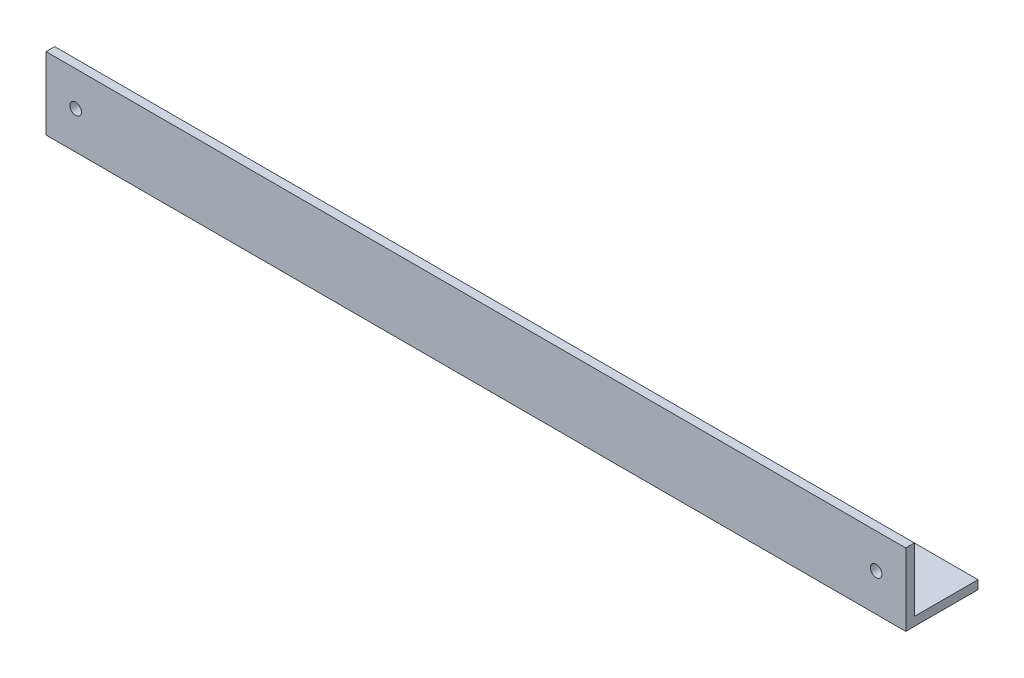
from build123d import *

# Parameters (mm, degrees)
EXTRUDE_2_DEPTH     = 595
SKETCH_2_R          = 4
CUT_EXTRUDE_1_DEPTH = 51


with BuildPart() as part:
    # Эскиз1 → Вытянуть-Тонкостенный2 (new body)
    with BuildSketch(Plane(origin=(0, 0, 0), x_dir=(0, 0, -1), z_dir=(1, 0, 0))):
        Polygon((0, 50), (0, 0), (50, 0), (50, 6), (6, 6), (6, 50), align=None)
    extrude(amount=EXTRUDE_2_DEPTH)

    # Эскиз2 → Вырез-Вытянуть1 (cut, through all)
    with BuildSketch(Plane.XY):
        with Locations((20.5, 26)):
            Circle(SKETCH_2_R)
        with Locations((574.5, 26)):
            Circle(SKETCH_2_R)
    extrude(amount=-CUT_EXTRUDE_1_DEPTH, mode=Mode.SUBTRACT)


solid = part.part
